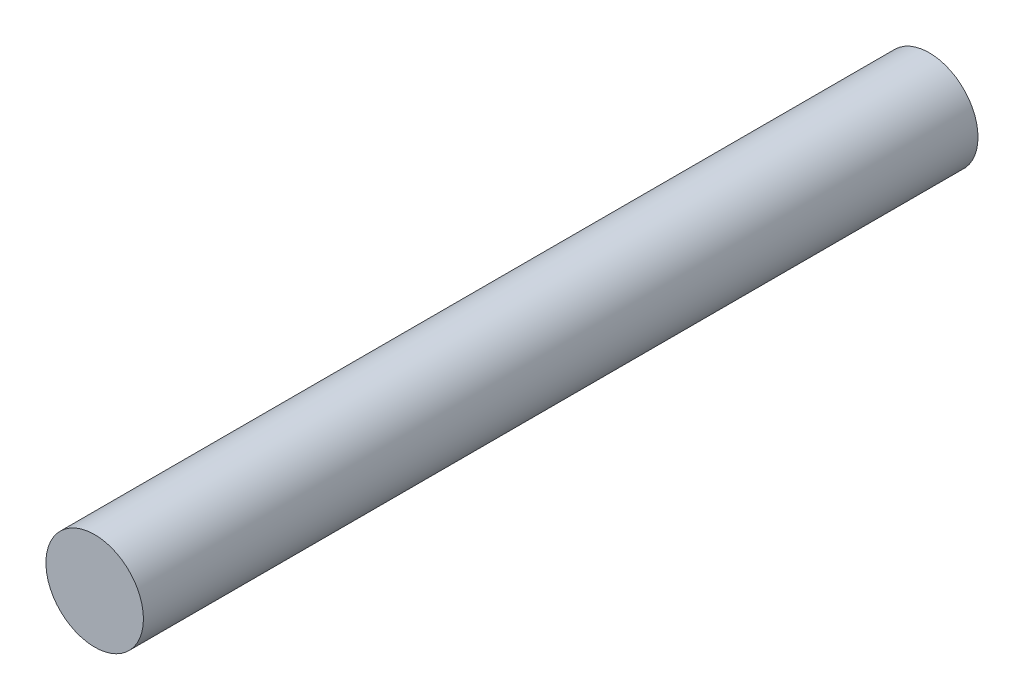
from build123d import *

# Parameters (mm, degrees)
SKETCH1_R           = 2.775
BOSS_EXTRUDE1_DEPTH = 47.5


with BuildPart() as part:
    # Sketch1 → Boss-Extrude1 (new body)
    with BuildSketch(Plane.XY):
        Circle(SKETCH1_R)
    extrude(amount=BOSS_EXTRUDE1_DEPTH)


solid = part.part
